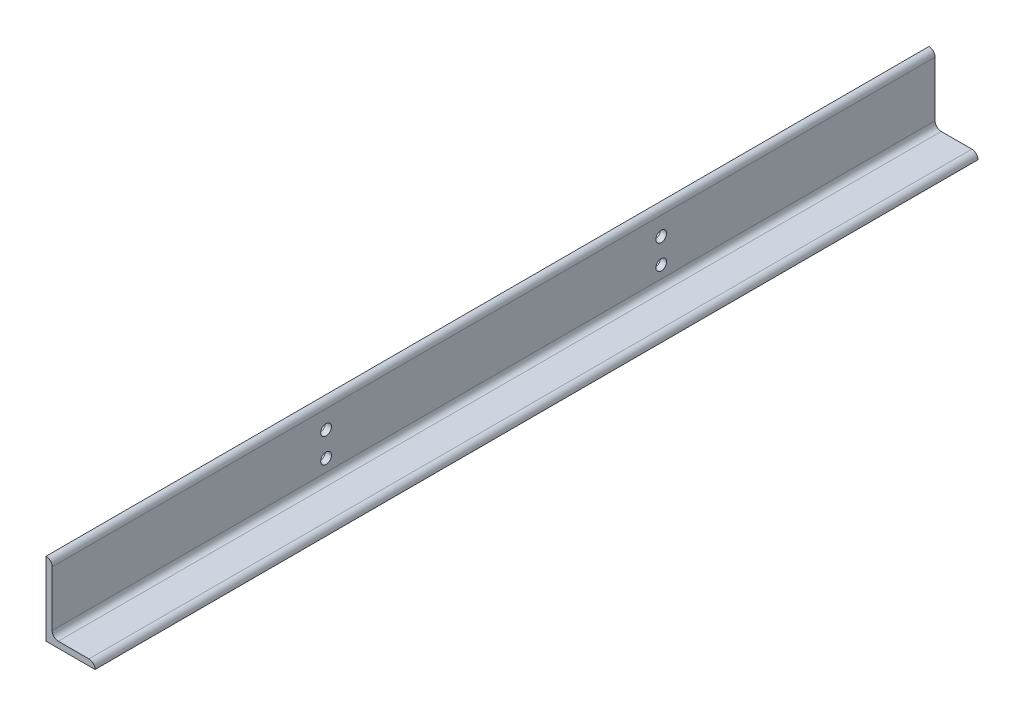
from build123d import *

# Parameters (mm, degrees)
BOSS_EXTRUDE1_DEPTH = 914.4
CUT_EXTRUDE1_REACH  = 103.6
SKETCH2_R           = 11.1125


with BuildPart() as part:
    # Sketch1 → Boss-Extrude1 (new body, symmetric)
    with BuildSketch(Plane.XY):
        with BuildLine():
            Line((0, 0), (0, 152.4))
            Line((0, 152.4), (0.00508, 152.4))
            ThreePointArc((0.00508, 152.4), (8.981744019, 148.681744019), (12.7, 139.70508))
            Line((12.7, 139.70508), (12.7, 25.4))
            ThreePointArc((12.7, 25.4), (16.419743879, 16.419743879), (25.4, 12.7))
            Line((25.4, 12.7), (88.90508, 12.7))
            ThreePointArc((88.90508, 12.7), (97.881744019, 8.981744019), (101.6, 0.00508))
            Line((101.6, 0.00508), (101.6, 0))
            Line((101.6, 0), (0, 0))
        make_face()
    extrude(amount=BOSS_EXTRUDE1_DEPTH, both=True)

    # Sketch2 → Cut-Extrude1 (cut, up to next)
    with BuildSketch(Plane.ZY, mode=Mode.PRIVATE) as cut_extrude1_sk1:
        with Locations((346.964, 50.8)):
            Circle(SKETCH2_R)
    cut_extrude1_tool1 = extrude(cut_extrude1_sk1.sketch, amount=-CUT_EXTRUDE1_REACH, mode=Mode.PRIVATE) & part.part
    add(cut_extrude1_tool1.solids().sort_by_distance((0, 50.8, 346.964))[0], mode=Mode.SUBTRACT)
    # Sketch2 → Cut-Extrude1 (cut, up to next)
    with BuildSketch(Plane.ZY, mode=Mode.PRIVATE) as cut_extrude1_sk2:
        with Locations((-347.218, 50.8)):
            Circle(SKETCH2_R)
    cut_extrude1_tool2 = extrude(cut_extrude1_sk2.sketch, amount=-CUT_EXTRUDE1_REACH, mode=Mode.PRIVATE) & part.part
    add(cut_extrude1_tool2.solids().sort_by_distance((0, 50.8, -347.218))[0], mode=Mode.SUBTRACT)
    # Sketch2 → Cut-Extrude1 (cut, up to next)
    with BuildSketch(Plane.ZY, mode=Mode.PRIVATE) as cut_extrude1_sk3:
        with Locations((346.964, 101.791886097)):
            Circle(SKETCH2_R)
    cut_extrude1_tool3 = extrude(cut_extrude1_sk3.sketch, amount=-CUT_EXTRUDE1_REACH, mode=Mode.PRIVATE) & part.part
    add(cut_extrude1_tool3.solids().sort_by_distance((0, 101.791886, 346.964))[0], mode=Mode.SUBTRACT)
    # Sketch2 → Cut-Extrude1 (cut, up to next)
    with BuildSketch(Plane.ZY, mode=Mode.PRIVATE) as cut_extrude1_sk4:
        with Locations((-347.218, 101.6)):
            Circle(SKETCH2_R)
    cut_extrude1_tool4 = extrude(cut_extrude1_sk4.sketch, amount=-CUT_EXTRUDE1_REACH, mode=Mode.PRIVATE) & part.part
    add(cut_extrude1_tool4.solids().sort_by_distance((0, 101.6, -347.218))[0], mode=Mode.SUBTRACT)


solid = part.part
